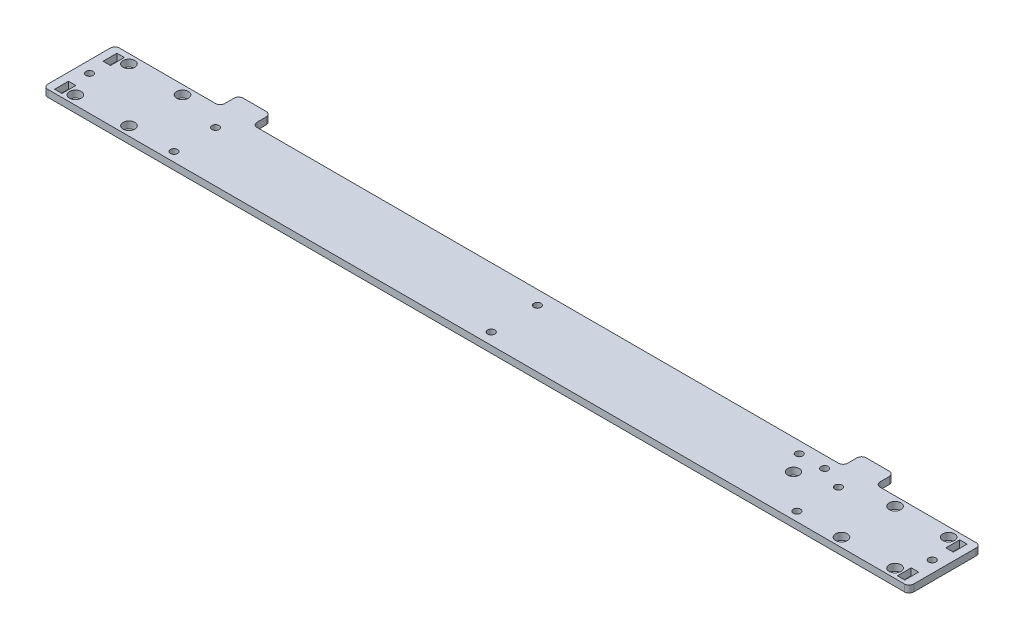
from build123d import *

# Parameters (mm, degrees)
CROQUIS1_R              = 1.55
CROQUIS1_R_2            = 2.55
CROQUIS1_R_3            = 2.5
CROQUIS1_W              = 3.2
CROQUIS1_H              = 6
SALIENTE_EXTRUIR1_DEPTH = 3
REDONDEO2_R             = 2


with BuildPart() as part:
    # Croquis1 → Saliente-Extruir1 (new body)
    with BuildSketch(Plane(origin=(0, 0, 0), x_dir=(1, 0, 0), z_dir=(0, 1, 0))):
        Polygon((0, 0), (375, 0), (375, 31), (329.4, 31), (329.4, 39), (315.4, 39), (315.4, 31), (59.6, 31), (59.6, 39), (45.6, 39), (45.6, 31), (0, 31), align=None)
        with Locations((5, 15)):
            Circle(CROQUIS1_R, mode=Mode.SUBTRACT)
        with Locations((370, 15)):
            Circle(CROQUIS1_R, mode=Mode.SUBTRACT)
        with Locations((10, 27.1)):
            Circle(CROQUIS1_R_2, mode=Mode.SUBTRACT)
        with Locations((33.2, 27.1)):
            Circle(CROQUIS1_R_2, mode=Mode.SUBTRACT)
        with Locations((33.2, 3.9)):
            Circle(CROQUIS1_R_2, mode=Mode.SUBTRACT)
        with Locations((10, 3.9)):
            Circle(CROQUIS1_R_2, mode=Mode.SUBTRACT)
        with Locations((365, 3.9)):
            Circle(CROQUIS1_R_2, mode=Mode.SUBTRACT)
        with Locations((341.8, 3.9)):
            Circle(CROQUIS1_R_2, mode=Mode.SUBTRACT)
        with Locations((365, 27.1)):
            Circle(CROQUIS1_R_2, mode=Mode.SUBTRACT)
        with Locations((341.8, 27.1)):
            Circle(CROQUIS1_R_2, mode=Mode.SUBTRACT)
        with Locations((189, 25)):
            Circle(CROQUIS1_R, mode=Mode.SUBTRACT)
        with Locations((189, 5)):
            Circle(CROQUIS1_R, mode=Mode.SUBTRACT)
        with Locations((52.6, 22)):
            Circle(CROQUIS1_R, mode=Mode.SUBTRACT)
        with Locations((52.6, 4)):
            Circle(CROQUIS1_R, mode=Mode.SUBTRACT)
        with Locations((322.4, 22)):
            Circle(CROQUIS1_R, mode=Mode.SUBTRACT)
        with Locations((322.4, 4)):
            Circle(CROQUIS1_R, mode=Mode.SUBTRACT)
        with Locations((312.4, 26)):
            Circle(CROQUIS1_R, mode=Mode.SUBTRACT)
        with Locations((301.4, 26)):
            Circle(CROQUIS1_R, mode=Mode.SUBTRACT)
        with Locations((306.9, 18)):
            Circle(CROQUIS1_R_3, mode=Mode.SUBTRACT)
        with Locations((370, 4.5)):
            Rectangle(CROQUIS1_W, CROQUIS1_H, mode=Mode.SUBTRACT)
        with Locations((5, 25.5)):
            Rectangle(CROQUIS1_W, CROQUIS1_H, mode=Mode.SUBTRACT)
        with Locations((5, 4.5)):
            Rectangle(CROQUIS1_W, CROQUIS1_H, mode=Mode.SUBTRACT)
        with Locations((370, 25.5)):
            Rectangle(CROQUIS1_W, CROQUIS1_H, mode=Mode.SUBTRACT)
    extrude(amount=SALIENTE_EXTRUIR1_DEPTH)

    # Redondeo2
    redondeo2_edges = [part.edges().sort_by_distance(p)[0] for p in [
        (0, 1.5, -31),
        (45.6, 1.5, -31),
        (45.6, 1.5, -39),
        (59.6, 1.5, -39),
        (59.6, 1.5, -31),
        (315.4, 1.5, -31),
        (315.4, 1.5, -39),
        (329.4, 1.5, -39),
        (329.4, 1.5, -31),
        (375, 1.5, -31),
        (375, 1.5, 0),
        (0, 1.5, 0),
    ]]
    fillet(redondeo2_edges, radius=REDONDEO2_R)


solid = part.part
